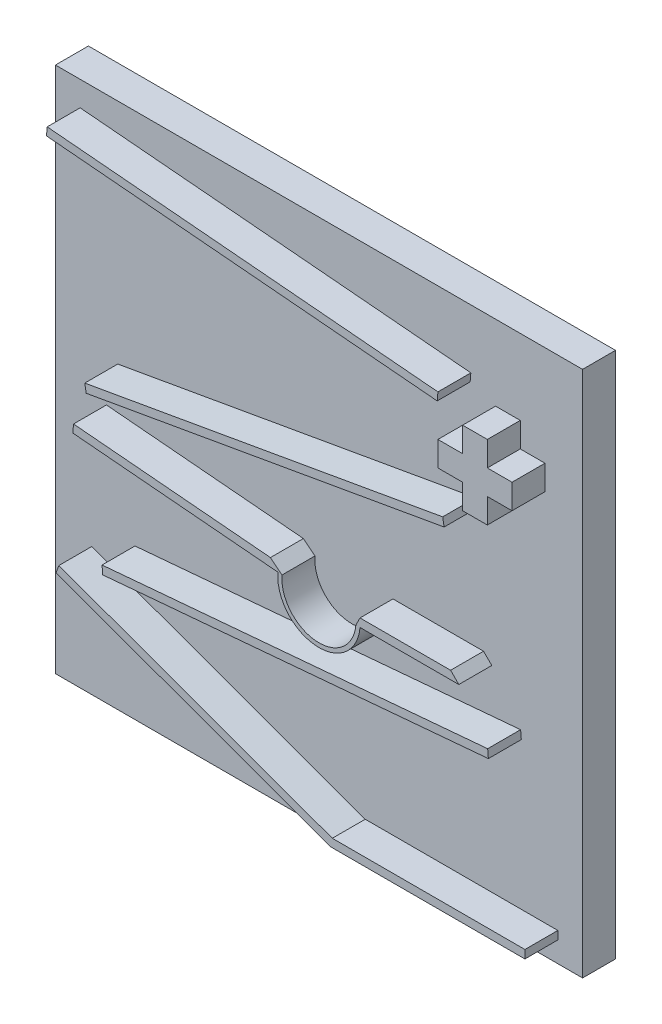
from build123d import *

# Parameters (mm, degrees)
BOSS_EXTRUDE2_DEPTH   = 40
BOSS_EXTRUDE2_2_DEPTH = 40
BOSS_EXTRUDE2_3_DEPTH = 40
BOSS_EXTRUDE2_4_DEPTH = 40
BOSS_EXTRUDE2_5_DEPTH = 40
BOSS_EXTRUDE2_6_DEPTH = 40
SKETCH1_4_W           = 640
SKETCH1_4_H           = 640
BOSS_EXTRUDE3_DEPTH   = 40


with BuildPart() as part:
    # Sketch1 → Boss-Extrude2 (new body)
    with BuildSketch(Plane.XY):
        Polygon((125.634221906, 248.154756102), (-348.735472044, 289.656726643), (-349.607029472, 279.694779662), (124.762664478, 238.192809121), align=None)
    extrude(amount=BOSS_EXTRUDE2_DEPTH)


with BuildPart() as body_2:
    # Sketch1 → Boss-Extrude2 2 (new body)
    with BuildSketch(Plane.XY):
        Polygon((155.634221906, 198.154756102), (125.634221906, 198.154756102), (125.634221906, 168.154756102), (155.634221906, 168.154756102), (155.634221906, 138.154756102), (185.634221906, 138.154756102), (185.634221906, 168.154756102), (215.634221906, 168.154756102), (215.634221906, 198.154756102), (185.634221906, 198.154756102), (185.634221906, 228.154756102), (155.634221906, 228.154756102), align=None)
    extrude(amount=BOSS_EXTRUDE2_2_DEPTH)


with BuildPart() as body_3:
    # Sketch1 → Boss-Extrude2 3 (new body)
    with BuildSketch(Plane.XY):
        Polygon((133.180509115, 109.808649113), (131.444027338, 119.656726643), (-303.127612508, 43.030021487), (-301.391130731, 33.181943957), align=None)
    extrude(amount=BOSS_EXTRUDE2_3_DEPTH)


with BuildPart() as body_4:
    # Sketch1 → Boss-Extrude2 4 (new body)
    with BuildSketch(Plane.XY):
        with BuildLine():
            Line((-77.709800851, -27.735434302), (-316.796528393, -6.818056043))
            Line((-316.796528393, -6.818056043), (-317.668085821, -16.780003024))
            Line((-317.668085821, -16.780003024), (-68.619411298, -38.568938711))
            ThreePointArc((-68.619411298, -38.568938711), (-22.949613754, -92.755040275), (31.036264765, -46.848734272))
            Line((31.036264765, -46.848734272), (151.036264765, -46.848734272))
            Line((151.036264765, -46.848734272), (141.036264765, -36.848734272))
            Line((141.036264765, -36.848734272), (31.036264765, -36.848734272))
            Line((31.036264765, -36.848734272), (26.019085021, -46.848734272))
            ThreePointArc((26.019085021, -46.848734272), (-22.731684817, -87.755487262), (-63.638437807, -39.004717424))
            Line((-63.638437807, -39.004717424), (-77.709800851, -27.735434302))
        make_face()
    extrude(amount=BOSS_EXTRUDE2_4_DEPTH)


with BuildPart() as body_5:
    # Sketch1 → Boss-Extrude2 5 (new body)
    with BuildSketch(Plane.XY):
        Polygon((186.907822192, -106.810681252), (186.036264765, -96.848734272), (-282.175243338, -137.811933363), (-281.303685911, -147.773880344), align=None)
    extrude(amount=BOSS_EXTRUDE2_5_DEPTH)


with BuildPart() as body_6:
    # Sketch1 → Boss-Extrude2 6 (new body)
    with BuildSketch(Plane.XY):
        Polygon((-2.599325132, -285.343273357), (-334.573935055, -164.514396813), (-337.994136488, -173.911323021), (-4.362594939, -295.343273357), (231.264527956, -295.343273357), (231.264527956, -285.343273357), align=None)
    extrude(amount=BOSS_EXTRUDE2_6_DEPTH)


with BuildPart() as body_7:
    # Sketch1_4 → Boss-Extrude3 (new body)
    with BuildSketch(Plane.XY):
        with Locations((-58.735472044, -0.343273357)):
            Rectangle(SKETCH1_4_W, SKETCH1_4_H)
        with BuildLine():
            Line((-317.668085821, -16.780003024), (-316.796528393, -6.818056043))
            Line((-316.796528393, -6.818056043), (-77.709800851, -27.735434302))
            Line((-77.709800851, -27.735434302), (-63.638437807, -39.004717424))
            ThreePointArc((-63.638437807, -39.004717424), (-22.731684817, -87.755487262), (26.019085021, -46.848734272))
            Line((26.019085021, -46.848734272), (31.036264765, -36.848734272))
            Line((31.036264765, -36.848734272), (141.036264765, -36.848734272))
            Line((141.036264765, -36.848734272), (151.036264765, -46.848734272))
            Line((151.036264765, -46.848734272), (31.036264765, -46.848734272))
            ThreePointArc((31.036264765, -46.848734272), (-22.949613754, -92.755040275), (-68.619411298, -38.568938711))
            Line((-68.619411298, -38.568938711), (-317.668085821, -16.780003024))
        make_face(mode=Mode.SUBTRACT)
        Polygon((-337.994136488, -173.911323021), (-334.573935055, -164.514396813), (-2.599325132, -285.343273357), (231.264527956, -285.343273357), (231.264527956, -295.343273357), (-4.362594939, -295.343273357), align=None, mode=Mode.SUBTRACT)
        Polygon((-282.175243338, -137.811933363), (186.036264765, -96.848734272), (186.907822192, -106.810681252), (-281.303685911, -147.773880344), align=None, mode=Mode.SUBTRACT)
        Polygon((-303.127612508, 43.030021487), (131.444027338, 119.656726643), (133.180509115, 109.808649113), (-301.391130731, 33.181943957), align=None, mode=Mode.SUBTRACT)
        Polygon((-349.607029472, 279.694779662), (-348.735472044, 289.656726643), (125.634221906, 248.154756102), (124.762664478, 238.192809121), align=None, mode=Mode.SUBTRACT)
        Polygon((125.634221906, 168.154756102), (125.634221906, 198.154756102), (155.634221906, 198.154756102), (155.634221906, 228.154756102), (185.634221906, 228.154756102), (185.634221906, 198.154756102), (215.634221906, 198.154756102), (215.634221906, 168.154756102), (185.634221906, 168.154756102), (185.634221906, 138.154756102), (155.634221906, 138.154756102), (155.634221906, 168.154756102), align=None, mode=Mode.SUBTRACT)
    extrude(amount=-BOSS_EXTRUDE3_DEPTH)


solid = Compound([part.part, body_2.part, body_3.part, body_4.part, body_5.part, body_6.part, body_7.part])
